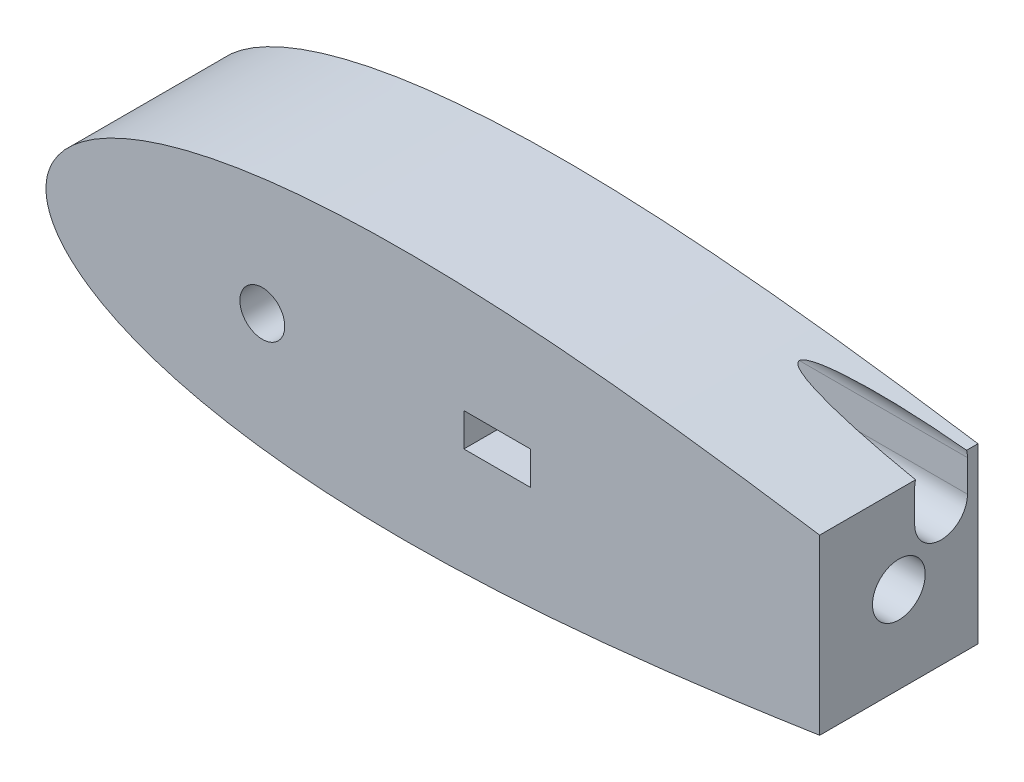
from build123d import *

# Parameters (mm, degrees)
BOSS_EXTRUDE1_DEPTH     = 76.2
SKETCH3_R               = 10.795
CUT_EXTRUDE2_DEPTH      = 76.2
SKETCH6_R               = 6.35
CUT_EXTRUDE3_DEPTH      = 53.34
CUT_EXTRUDE3_DEPTH_BACK = 0.000254
SKETCH7_R               = 1.5875
CUT_EXTRUDE4_DEPTH      = 30.48
SKETCH8_W               = 304.8
SKETCH8_H               = 127
CUT_EXTRUDE5_DEPTH      = 76.2
SKETCH9_R               = 12.7
CUT_EXTRUDE6_DEPTH      = 101.6
SKETCH10_R              = 3.175
CUT_EXTRUDE7_DEPTH      = 57.15
SKETCH11_R              = 5.08
CUT_EXTRUDE8_DEPTH      = 6.35
SKETCH12_R              = 3.175
CUT_EXTRUDE9_DEPTH      = 6.35
CUT_EXTRUDE10_DEPTH     = 198.458047838
SKETCH15_W              = 87.376
SKETCH15_H              = 60.96
CUT_EXTRUDE11_DEPTH     = 33.299999948
SKETCH17_W              = 32.000000008
SKETCH17_H              = 16.000000004
CUT_EXTRUDE12_DEPTH     = 50.8
SKETCH18_R              = 1.5
CUT_EXTRUDE13_DEPTH     = 25.4
SKETCH19_W              = 53.34
SKETCH19_H              = 21.59
CUT_EXTRUDE14_DEPTH     = 66.04
SKETCH21_W              = 28.440000016
SKETCH21_H              = 14.220000008
CUT_EXTRUDE15_DEPTH     = 50.8
SKETCH23_W              = 31.996000016
SKETCH23_H              = 18.284000008
CUT_EXTRUDE16_DEPTH     = 10.16
SKETCH24_W              = 53.34
SKETCH24_H              = 25.706256832
CUT_EXTRUDE17_DEPTH     = 50.8


with BuildPart() as part:
    # Sketch1 → Boss-Extrude1 (new body)
    with BuildSketch(Plane.XY):
        with BuildLine():
            Line((643.966787522, 0), (643.599082689, 0))
            Line((643.599082689, 0), (643.599082689, -1.016))
            ThreePointArc((643.599082689, -1.016), (643.872033494, -0.540245973), (643.966787522, 0))
        make_face()
        with BuildLine():
            Line((643.599082689, -1.016), (643.599082689, 0))
            Line((643.599082689, 0), (641.567082689, 0))
            ThreePointArc((641.567082689, 0), (642.269121423, -1.135922533), (643.599082689, -1.016))
        make_face()
        with BuildLine():
            Line((641.567082689, 0), (643.599082689, 0))
            Line((643.599082689, 0), (643.966787522, 0))
            ThreePointArc((643.966787522, 0), (643.547407924, 1.075012082), (642.510849283, 1.582039112))
            add(Edge.make_bspline(
                [(642.510849283, 1.582039112), (641.993392355, 1.625070631), (638.093728429, 1.953546407), (630.413817462, 2.663385493), (619.014124193, 3.849253664), (606.374988512, 5.304428983), (592.543922516, 7.037634907), (577.585454095, 9.050636147), (561.564270734, 11.338919625), (544.549749946, 13.890665375), (526.614143658, 16.687720753), (507.832591566, 19.705111663), (488.282710288, 22.911672601), (468.044367735, 26.27043606), (447.199424328, 29.739007432), (425.831595832, 33.270324121), (404.02631566, 36.813220545), (381.870662856, 40.313266856), (359.453314895, 43.713502532), (336.86454415, 46.955447457), (314.196207315, 49.979843895), (291.541767704, 52.727712704), (268.996310773, 55.141201012), (246.65655865, 57.164603829), (224.620860897, 58.745176641), (202.989192599, 59.8341217), (181.863132616, 60.387506142), (161.345829027, 60.366961324), (141.542033828, 59.739895824), (122.558104573, 58.481758104), (104.502313427, 56.574303932), (87.485018636, 54.008935199), (71.619696083, 50.784752003), (57.023709725, 46.912543066), (43.82045433, 42.41500246), (32.141645239, 37.332204029), (22.129107375, 31.731455339), (13.932423524, 25.726412106), (7.689616489, 19.513207632), (3.463136343, 13.420354421), (1.106333228, 7.923389435), (0.154611582, 3.513796615), (0, 1.007496172), (0, 0)],
                knots=[0.020157042, 0.020157042, 0.020157042, 0.020157042, 0.021270888, 0.028552555, 0.036780684, 0.045920102, 0.055931764, 0.066772884, 0.07839713, 0.090754827, 0.103793165, 0.117456432, 0.131686226, 0.146421738, 0.161599998, 0.177156133, 0.193023668, 0.209134786, 0.225420633, 0.241811602, 0.258237647, 0.274628557, 0.290914287, 0.307025229, 0.322892517, 0.338448342, 0.353626207, 0.368361232, 0.382590428, 0.396252961, 0.409290412, 0.42164701, 0.433269881, 0.444109249, 0.45411864, 0.463255055, 0.471479114, 0.478755289, 0.485052318, 0.490344026, 0.494609833, 0.497833231, 0.5, 0.5, 0.5, 0.5], degree=3))
            Line((0, 0), (27.94, 0))
            ThreePointArc((27.94, 0), (40.64, 12.7), (53.34, 0))
            Line((53.34, 0), (93.345, 0))
            ThreePointArc((93.345, 0), (104.14, 10.795), (114.935, 0))
            Line((114.935, 0), (460.660965279, 0))
            Line((460.660965279, 0), (473.360965279, 0))
            Line((473.360965279, 0), (641.567082689, 0))
        make_face()
        with BuildLine():
            ThreePointArc((642.510849283, -1.582039112), (643.111845681, -1.408373102), (643.599082689, -1.016))
            ThreePointArc((643.599082689, -1.016), (642.269121423, -1.135922533), (641.567082689, 0))
            Line((641.567082689, 0), (473.360965279, 0))
            Line((473.360965279, 0), (460.660965279, 0))
            Line((460.660965279, 0), (114.935, 0))
            ThreePointArc((114.935, 0), (104.14, -10.795), (93.345, 0))
            Line((93.345, 0), (53.34, 0))
            ThreePointArc((53.34, 0), (40.64, -12.7), (27.94, 0))
            Line((27.94, 0), (0, 0))
            add(Edge.make_bspline(
                [(0, 0), (0, -1.007496172), (0.154611582, -3.513796615), (1.106333228, -7.923389435), (3.463136343, -13.420354421), (7.689616489, -19.513207632), (13.932423524, -25.726412106), (22.129107375, -31.731455339), (32.141645239, -37.332204029), (43.82045433, -42.41500246), (57.023709725, -46.912543066), (71.619696083, -50.784752003), (87.485018636, -54.008935199), (104.502313427, -56.574303932), (122.558104573, -58.481758104), (141.542033828, -59.739895824), (161.345829027, -60.366961324), (181.863132616, -60.387506142), (202.989192599, -59.8341217), (224.620860897, -58.745176641), (246.65655865, -57.164603829), (268.996310773, -55.141201012), (291.541767704, -52.727712704), (314.196207315, -49.979843895), (336.86454415, -46.955447457), (359.453314895, -43.713502532), (381.870662856, -40.313266856), (404.02631566, -36.813220545), (425.831595832, -33.270324121), (447.199424328, -29.739007432), (468.044367735, -26.27043606), (488.282710288, -22.911672601), (507.832591566, -19.705111663), (526.614143658, -16.687720753), (544.549749946, -13.890665375), (561.564270734, -11.338919625), (577.585454095, -9.050636147), (592.543922516, -7.037634907), (606.374988512, -5.304428983), (619.014124193, -3.849253664), (630.413817462, -2.663385493), (638.093728429, -1.953546407), (641.993392355, -1.625070631), (642.510849283, -1.582039112)],
                knots=[0.5, 0.5, 0.5, 0.5, 0.502166769, 0.505390167, 0.509655974, 0.514947682, 0.521244711, 0.528520886, 0.536744945, 0.54588136, 0.555890751, 0.566730119, 0.57835299, 0.590709588, 0.603747039, 0.617409572, 0.631638768, 0.646373793, 0.661551658, 0.677107483, 0.692974771, 0.709085713, 0.725371443, 0.741762353, 0.758188398, 0.774579367, 0.790865214, 0.806976332, 0.822843867, 0.838400002, 0.853578262, 0.868313774, 0.882543568, 0.896206835, 0.909245173, 0.92160287, 0.933227116, 0.944068236, 0.954079898, 0.963219316, 0.971447445, 0.978729112, 0.979842958, 0.979842958, 0.979842958, 0.979842958], degree=3))
        make_face()
        with BuildLine():
            ThreePointArc((643.966787522, 0), (643.872033494, -0.540245973), (643.599082689, -1.016))
            ThreePointArc((643.599082689, -1.016), (643.111845681, -1.408373102), (642.510849283, -1.582039112))
            add(Edge.make_bspline(
                [(642.510849283, -1.582039112), (644.922074617, -1.381522545), (649.798936594, -1.000308437), (656.504964311, -0.543558383), (662.850933168, -0.234427605), (666.344759683, -0.054696708), (670.56, -0.015678595), (670.56, 0)],
                knots=[0.979842958, 0.979842958, 0.979842958, 0.979842958, 0.985033212, 0.990332793, 0.994605218, 0.997832222, 1, 1, 1, 1], degree=3))
            add(Edge.make_bspline(
                [(670.56, 0), (670.56, 0.015678595), (666.344759683, 0.054696708), (662.850933168, 0.234427605), (656.504964311, 0.543558383), (649.798936594, 1.000308437), (644.922074617, 1.381522545), (642.510849283, 1.582039112)],
                knots=[0, 0, 0, 0, 0.002167778, 0.005394782, 0.009667207, 0.014966788, 0.020157042, 0.020157042, 0.020157042, 0.020157042], degree=3))
            ThreePointArc((642.510849283, 1.582039112), (643.547407924, 1.075012082), (643.966787522, 0))
        make_face()
        with BuildLine():
            ThreePointArc((53.34, 0), (40.64, 12.7), (27.94, 0))
            Line((27.94, 0), (53.34, 0))
        make_face()
        with BuildLine():
            Line((53.34, 0), (27.94, 0))
            ThreePointArc((27.94, 0), (40.64, -12.7), (53.34, 0))
        make_face()
        with BuildLine():
            ThreePointArc((93.345, 0), (104.14, -10.795), (114.935, 0))
            Line((114.935, 0), (93.345, 0))
        make_face()
        with BuildLine():
            Line((93.345, 0), (114.935, 0))
            ThreePointArc((114.935, 0), (104.14, 10.795), (93.345, 0))
        make_face()
    extrude(amount=BOSS_EXTRUDE1_DEPTH)

    # Sketch3 → Cut-Extrude2 (cut)
    with BuildSketch(Plane.XY.offset(76.2)):
        with Locations((104.139232412, 0)):
            Circle(SKETCH3_R)
    extrude(amount=-CUT_EXTRUDE2_DEPTH, mode=Mode.SUBTRACT)

    # Sketch6 → Cut-Extrude3 (cut, two sides)
    with BuildSketch(Plane(origin=(0, 0, 0), x_dir=(0, 0, -1), z_dir=(1, 0, 0))) as cut_extrude3_sk:
        with Locations((-20.32, 0)):
            Circle(SKETCH6_R)
    extrude(amount=CUT_EXTRUDE3_DEPTH, mode=Mode.SUBTRACT)
    extrude(cut_extrude3_sk.sketch, amount=-CUT_EXTRUDE3_DEPTH_BACK, mode=Mode.SUBTRACT)

    # Sketch7 → Cut-Extrude4 (cut)
    with BuildSketch(Plane(origin=(0, 0, 0), x_dir=(-1, 0, 0), z_dir=(0, 0, -1))):
        with Locations((-38.1, 0)):
            Circle(SKETCH7_R)
        with Locations((-50.8, 0)):
            Circle(SKETCH7_R)
    extrude(amount=-CUT_EXTRUDE4_DEPTH, mode=Mode.SUBTRACT)

    # Sketch8 → Cut-Extrude5 (cut)
    with BuildSketch(Plane(origin=(0, 0, 0), x_dir=(-1, 0, 0), z_dir=(0, 0, -1))):
        with Locations((-524.843319628, 0.490119432)):
            Rectangle(SKETCH8_W, SKETCH8_H)
    extrude(amount=-CUT_EXTRUDE5_DEPTH, mode=Mode.SUBTRACT)

    # Sketch9 → Cut-Extrude6 (cut)
    with BuildSketch(Plane(origin=(372.443319628, 0, 0), x_dir=(0, 0, -1), z_dir=(1, 0, 0))):
        with Locations((-38.1, 0)):
            Circle(SKETCH9_R)
    extrude(amount=-CUT_EXTRUDE6_DEPTH, mode=Mode.SUBTRACT)

    # Sketch10 → Cut-Extrude7 (cut)
    with BuildSketch(Plane(origin=(0, 0, 0), x_dir=(-1, 0, 0), z_dir=(0, 0, -1))):
        with Locations((-343.868319647, 0)):
            Circle(SKETCH10_R)
        with Locations((-286.718319647, 0)):
            Circle(SKETCH10_R)
    extrude(amount=-CUT_EXTRUDE7_DEPTH, mode=Mode.SUBTRACT)

    # Sketch11 → Cut-Extrude8 (cut)
    with BuildSketch(Plane(origin=(0, 0, 0), x_dir=(-1, 0, 0), z_dir=(0, 0, -1))):
        with Locations((-286.718319647, 0)):
            Circle(SKETCH11_R)
        with Locations((-343.868319647, 0)):
            Circle(SKETCH11_R)
    extrude(amount=-CUT_EXTRUDE8_DEPTH, mode=Mode.SUBTRACT)

    # Sketch12 → Cut-Extrude9 (cut)
    with BuildSketch(Plane(origin=(0, 0, 0), x_dir=(-1, 0, 0), z_dir=(0, 0, -1))):
        with Locations((-38.1, 0)):
            Circle(SKETCH12_R)
        with Locations((-50.8, 0)):
            Circle(SKETCH12_R)
    extrude(amount=-CUT_EXTRUDE9_DEPTH, mode=Mode.SUBTRACT)

    # Sketch13 → Cut-Extrude10 (cut)
    with BuildSketch(Plane(origin=(372.443319628, 0, 0), x_dir=(0, 0, -1), z_dir=(1, 0, 0))):
        with BuildLine():
            Line((-30.48, 23.232341673), (-30.48, 38.472341673))
            ThreePointArc((-30.48, 38.472341673), (-17.78, 51.172341673), (-5.08, 38.472341673))
            Line((-5.08, 38.472341673), (-5.08, 23.232341673))
            ThreePointArc((-5.08, 23.232341673), (-17.78, 10.532341673), (-30.48, 23.232341673))
        make_face()
    extrude(amount=-CUT_EXTRUDE10_DEPTH, mode=Mode.SUBTRACT)

    # Sketch15 → Cut-Extrude11 (cut)
    with BuildSketch(Plane(origin=(0, 0, 0), x_dir=(-1, 0, 0), z_dir=(0, 0, -1))):
        with Locations((-217.673271809, 0)):
            Rectangle(SKETCH15_W, SKETCH15_H)
    extrude(amount=-CUT_EXTRUDE11_DEPTH, mode=Mode.SUBTRACT)

    # Sketch17 → Cut-Extrude12 (cut)
    with BuildSketch(Plane(origin=(0, 0, 33.299999948), x_dir=(-1, 0, 0), z_dir=(0, 0, -1))):
        with Locations((-217.171095775, 0)):
            Rectangle(SKETCH17_W, SKETCH17_H)
    extrude(amount=-CUT_EXTRUDE12_DEPTH, mode=Mode.SUBTRACT)

    # Sketch18 → Cut-Extrude13 (cut)
    with BuildSketch(Plane(origin=(0, 0, 33.299999948), x_dir=(-1, 0, 0), z_dir=(0, 0, -1))):
        with Locations((-199.471095771, 0)):
            Circle(SKETCH18_R)
        with Locations((-234.871095681, 0)):
            Circle(SKETCH18_R)
    extrude(amount=-CUT_EXTRUDE13_DEPTH, mode=Mode.SUBTRACT)

    # Sketch19 → Cut-Extrude14 (cut)
    with BuildSketch(Plane(origin=(0, 0, 0), x_dir=(-1, 0, 0), z_dir=(0, 0, -1))):
        with Locations((-139.373905779, 39.146670369)):
            Rectangle(SKETCH19_W, SKETCH19_H)
    extrude(amount=-CUT_EXTRUDE14_DEPTH, mode=Mode.SUBTRACT)

    # Sketch21 → Cut-Extrude15 (cut)
    with BuildSketch(Plane(origin=(0, 0, 0), x_dir=(-1, 0, 0), z_dir=(0, 0, -1))):
        with Locations((-139.374019907, 17.431670365)):
            Rectangle(SKETCH21_W, SKETCH21_H)
    extrude(amount=-CUT_EXTRUDE15_DEPTH, mode=Mode.SUBTRACT)

    # Sketch23 → Cut-Extrude16 (cut)
    with BuildSketch(Plane(origin=(0, 0, 0), x_dir=(-1, 0, 0), z_dir=(0, 0, -1))):
        with Locations((-139.374019907, 17.431670365)):
            Rectangle(SKETCH23_W, SKETCH23_H)
    extrude(amount=-CUT_EXTRUDE16_DEPTH, mode=Mode.SUBTRACT)

    # Sketch24 → Cut-Extrude17 (cut)
    with BuildSketch(Plane(origin=(0, 0, 0), x_dir=(-1, 0, 0), z_dir=(0, 0, -1))):
        with Locations((-139.140405298, -40.363228606)):
            Rectangle(SKETCH24_W, SKETCH24_H)
    extrude(amount=-CUT_EXTRUDE17_DEPTH, mode=Mode.SUBTRACT)


solid = part.part
